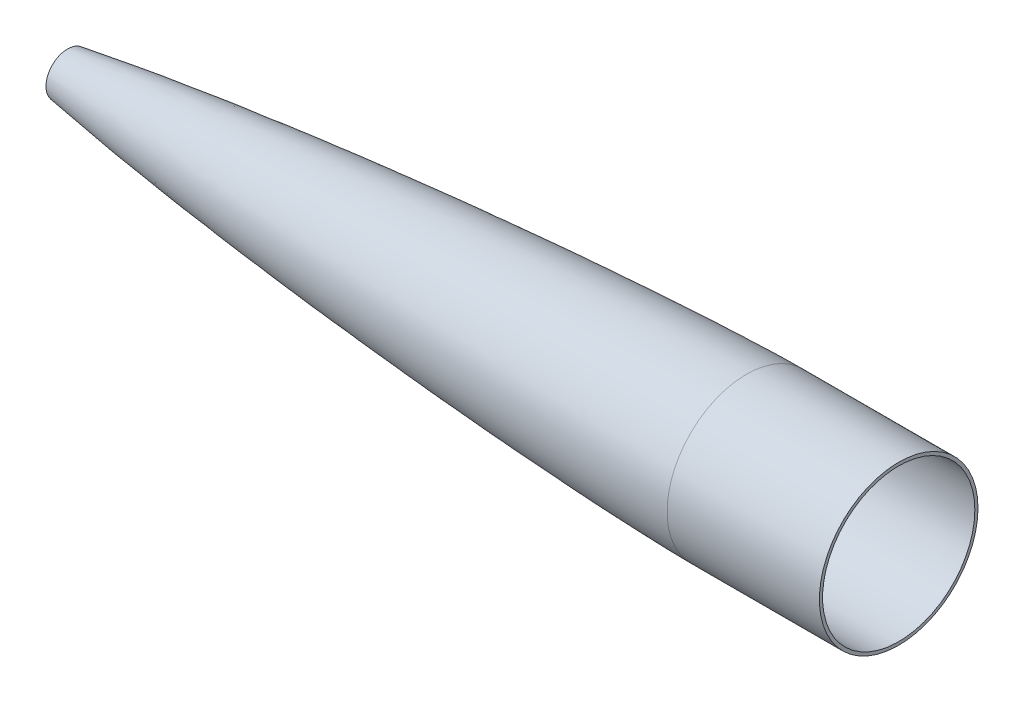
from build123d import *


with BuildPart() as part:
    # Sketch1 → Revolve1 (revolve)
    with BuildSketch(Plane.XY):
        with BuildLine():
            Line((762, 76.2), (914.4, 76.2))
            Line((914.4, 76.2), (914.4, 79.375))
            Line((914.4, 79.375), (762, 79.375))
            add(Edge.make_bspline(
                [(82.55, 21.60937563), (83.739317711, 21.803919016), (86.113124105, 22.189566566), (90.744392077, 22.93548366), (95.434501949, 23.672768813), (100.97871313, 24.53624011), (106.058901752, 25.311037661), (112.686881735, 26.309845163), (121.588127675, 27.623195976), (132.960891433, 29.257832455), (148.228562585, 31.379900401), (163.541095634, 33.42834242), (177.757213332, 35.268354344), (193.536259626, 37.254499166), (209.315792622, 39.186791314), (227.738082588, 41.370047954), (248.800039239, 43.773971398), (269.872934088, 46.093395626), (290.953613446, 48.332810696), (312.042727731, 50.49635438), (333.138872623, 52.587050652), (354.242048189, 54.607492331), (375.351537945, 56.559617254), (396.467163528, 58.444941036), (417.588515842, 60.264547843), (443.997107777, 62.457725293), (475.697958942, 64.960089086), (512.69683997, 67.690282987), (555.000098175, 70.544353132), (597.321403855, 73.117541014), (639.66026872, 75.385219331), (678.435776142, 77.141954164), (711.723143924, 78.353956499), (735.720930019, 78.997048552), (749.773416047, 79.258740095), (757.460733051, 79.348169215), (760.054576071, 79.368172133), (761.351521386, 79.373595664), (762, 79.375)],
                knots=[0.090454116, 0.090454116, 0.090454116, 0.090454116, 0.090454116, 0.097518757, 0.104583398, 0.111648039, 0.118712679, 0.125777318, 0.132841956, 0.146971233, 0.166926199, 0.186881164, 0.21513972, 0.229268998, 0.243398276, 0.271656831, 0.299915385, 0.328173941, 0.356432496, 0.38469105, 0.412949605, 0.44120816, 0.469466716, 0.497725271, 0.525983826, 0.554242381, 0.582500936, 0.639018047, 0.695535157, 0.752052267, 0.808569377, 0.865086487, 0.921603598, 0.959009279, 0.986169476, 0.993084738, 0.996542369, 1, 1, 1, 1, 1], degree=4))
            Line((82.55, 21.60937563), (82.55, 18.43437563))
            add(Edge.make_bspline(
                [(82.55, 18.43437563), (83.739317711, 18.628919016), (86.113124105, 19.014566566), (90.744392077, 19.76048366), (95.434501949, 20.497768813), (100.97871313, 21.36124011), (106.058901752, 22.136037661), (112.686881735, 23.134845163), (121.588127675, 24.448195976), (132.960891433, 26.082832455), (148.228562585, 28.204900402), (163.541095634, 30.25334242), (177.757213332, 32.093354344), (193.536259626, 34.079499167), (209.315792622, 36.011791314), (227.738082588, 38.195047954), (248.800039239, 40.598971398), (269.872934088, 42.918395627), (290.953613446, 45.157810696), (312.042727731, 47.32135438), (333.138872623, 49.412050652), (354.242048189, 51.432492331), (375.351537945, 53.384617254), (396.467163528, 55.269941036), (417.588515842, 57.089547843), (443.997107777, 59.282725293), (475.697958942, 61.785089086), (512.69683997, 64.515282987), (555.000098175, 67.369353132), (597.321403855, 69.942541014), (639.66026872, 72.210219331), (678.435776142, 73.966954164), (711.723143924, 75.178956499), (735.720930019, 75.822048552), (749.773416047, 76.083740095), (757.460733051, 76.173169215), (760.054576071, 76.193172133), (761.351521386, 76.198595664), (762, 76.2)],
                knots=[0.090454116, 0.090454116, 0.090454116, 0.090454116, 0.090454116, 0.097518757, 0.104583398, 0.111648039, 0.118712679, 0.125777318, 0.132841956, 0.146971233, 0.166926199, 0.186881164, 0.21513972, 0.229268998, 0.243398276, 0.271656831, 0.299915385, 0.328173941, 0.356432496, 0.38469105, 0.412949605, 0.44120816, 0.469466716, 0.497725271, 0.525983826, 0.554242381, 0.582500936, 0.639018047, 0.695535157, 0.752052267, 0.808569377, 0.865086487, 0.921603598, 0.959009279, 0.986169476, 0.993084738, 0.996542369, 1, 1, 1, 1, 1], degree=4))
        make_face()
    revolve(axis=Axis((993.46979012, 0, 0), (-1, 0, 0)))


solid = part.part
